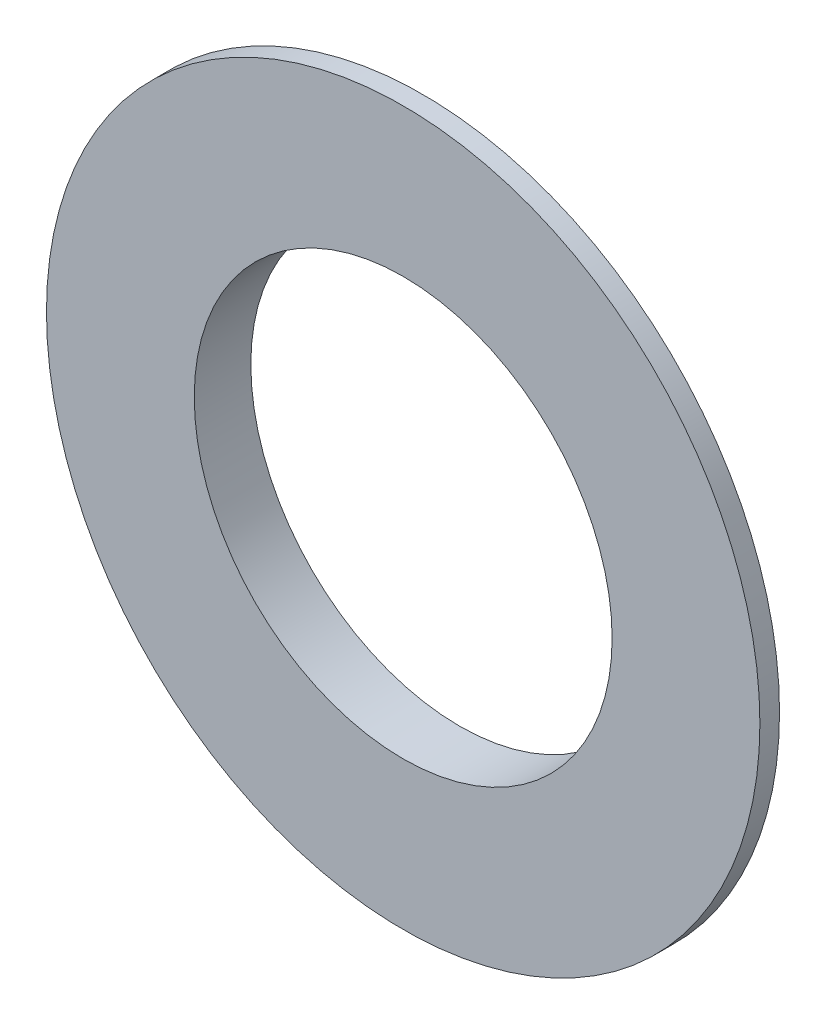
from build123d import *


with BuildPart() as part:
    # Sketch1 → Revolve1 (revolve)
    with BuildSketch(Plane(origin=(0, 0, 0), x_dir=(1, 0, 0), z_dir=(0, 1, 0))):
        Polygon((-18.916734694, 0), (-18.916734694, 1.040816327), (-11.08, 3), (-11.08, 0), align=None)
    revolve(axis=Axis((0, 0, 0), (0, 0, -1)))


solid = part.part
